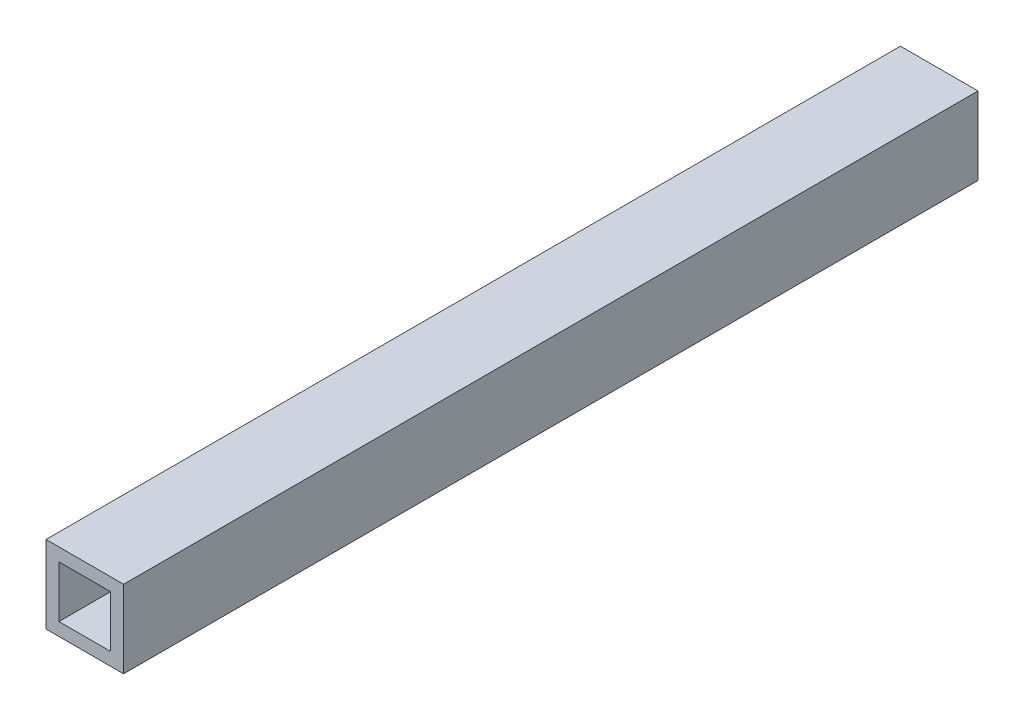
from build123d import *

# Parameters (mm, degrees)
SKETCH1_W           = 19.05
SKETCH1_H           = 19.05
BOSS_EXTRUDE1_DEPTH = 209.804
SKETCH2_W           = 12.7
SKETCH2_H           = 12.7
CUT_EXTRUDE1_DEPTH  = 210.804


with BuildPart() as part:
    # Sketch1 → Boss-Extrude1 (new body)
    with BuildSketch(Plane.XY):
        with Locations((-0.488461538, -3.948397436)):
            Rectangle(SKETCH1_W, SKETCH1_H)
    extrude(amount=BOSS_EXTRUDE1_DEPTH)

    # Sketch2 → Cut-Extrude1 (cut, through all)
    with BuildSketch(Plane(origin=(0, 0, 0), x_dir=(-1, 0, 0), z_dir=(0, 0, -1))):
        with Locations((0.488461538, -3.948397436)):
            Rectangle(SKETCH2_W, SKETCH2_H)
    extrude(amount=-CUT_EXTRUDE1_DEPTH, mode=Mode.SUBTRACT)


solid = part.part
